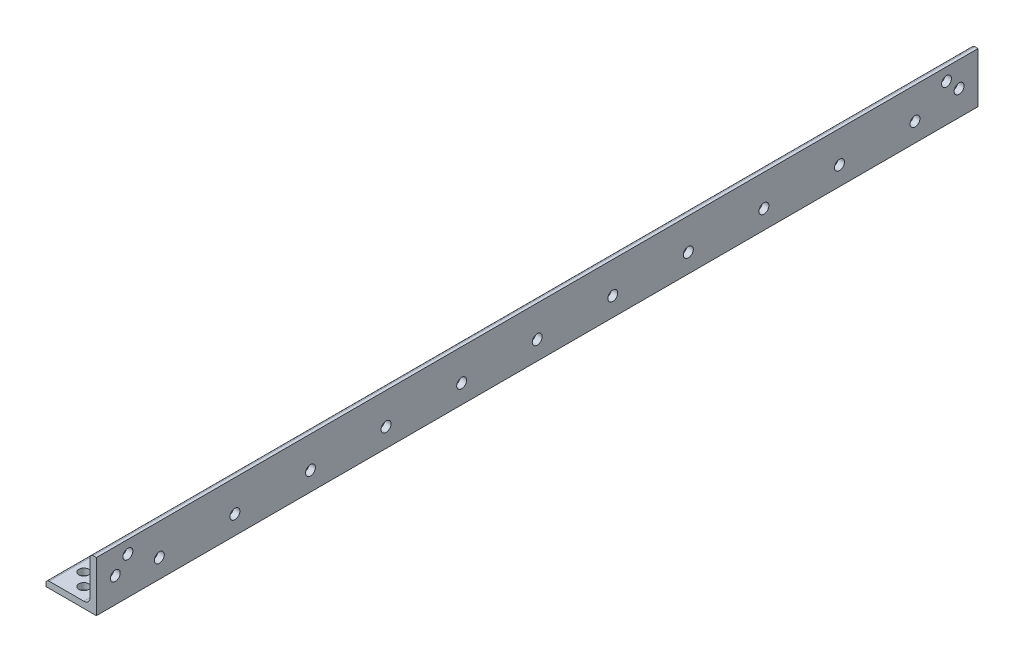
from build123d import *

# Parameters (mm, degrees)
BOSS_EXTRUDE1_DEPTH = 304.8
SKETCH7_W           = 25.4
SKETCH7_H           = 165.1
CUT_EXTRUDE1_DEPTH  = 254
SKETCH3_R           = 2.5
CUT_EXTRUDE2_DEPTH  = 254
SKETCH8_R           = 2.5
CUT_EXTRUDE4_DEPTH  = 254


with BuildPart() as part:
    # Sketch2 → Boss-Extrude1 (new, symmetric)
    with BuildSketch(Plane.XY):
        with BuildLine():
            Line((-12.7, -12.7), (12.7, -12.7))
            Line((12.7, -12.7), (12.7, 12.7))
            Line((12.7, 12.7), (11.1125, 12.7))
            ThreePointArc((11.1125, 12.7), (9.989967985, 12.235032015), (9.525, 11.1125))
            Line((9.525, 11.1125), (9.525, -6.35))
            ThreePointArc((9.525, -6.35), (8.59506403, -8.59506403), (6.35, -9.525))
            Line((6.35, -9.525), (-11.1125, -9.525))
            ThreePointArc((-11.1125, -9.525), (-12.235032015, -9.989967985), (-12.7, -11.1125))
            Line((-12.7, -11.1125), (-12.7, -12.7))
        make_face()
    extrude(amount=BOSS_EXTRUDE1_DEPTH, both=True)

    # Sketch7 → Cut-Extrude1 (cut)
    with BuildSketch(Plane.XZ.offset(12.7)):
        with Locations((0, 222.25)):
            Rectangle(SKETCH7_W, SKETCH7_H)
    extrude(amount=-CUT_EXTRUDE1_DEPTH, mode=Mode.SUBTRACT)

    # Sketch3 → Cut-Extrude2 (cut)
    with BuildSketch(Plane(origin=(0, 0, 0), x_dir=(1, 0, 0), z_dir=(0, 1, 0))):
        with Locations(Location((-6.35, 292.1, 0), (0, 0, 270))):
            Circle(SKETCH3_R)
        with Locations(Location((0, 298.45, 0), (0, 0, 270))):
            Circle(SKETCH3_R)
        with Locations(Location((0, 273.05, 0), (0, 0, 270))):
            Circle(SKETCH3_R)
        with Locations(Location((0, 234.95, 0), (0, 0, 270))):
            Circle(SKETCH3_R)
        with Locations(Location((0, 196.85, 0), (0, 0, 270))):
            Circle(SKETCH3_R)
        with Locations(Location((0, 158.75, 0), (0, 0, 270))):
            Circle(SKETCH3_R)
        with Locations(Location((0, 120.65, 0), (0, 0, 270))):
            Circle(SKETCH3_R)
        with Locations(Location((0, 82.55, 0), (0, 0, 270))):
            Circle(SKETCH3_R)
        with Locations(Location((0, 44.45, 0), (0, 0, 270))):
            Circle(SKETCH3_R)
        with Locations(Location((0, 6.35, 0), (0, 0, 270))):
            Circle(SKETCH3_R)
        with Locations(Location((0, -31.75, 0), (0, 0, 270))):
            Circle(SKETCH3_R)
        with Locations(Location((0, -69.85, 0), (0, 0, 270))):
            Circle(SKETCH3_R)
        with Locations(Location((0, -107.95, 0), (0, 0, 270))):
            Circle(SKETCH3_R)
        with Locations(Location((0, -133.35, 0), (0, 0, 270))):
            Circle(SKETCH3_R)
        with Locations(Location((-6.35, -127, 0), (0, 0, 270))):
            Circle(SKETCH3_R)
    extrude(amount=-CUT_EXTRUDE2_DEPTH, mode=Mode.SUBTRACT)

    # Sketch8 → Cut-Extrude4 (cut)
    with BuildSketch(Plane(origin=(12.7, 0, -12.7), x_dir=(0, 0, 1), z_dir=(-1, 0, 0))):
        with Locations(Location((136.525, 6.35, 0), (0, 0, 90))):
            Circle(SKETCH8_R)
        with Locations(Location((142.875, 0, 0), (0, 0, 90))):
            Circle(SKETCH8_R)
        with Locations(Location((120.65, -3.175, 0), (0, 0, 90))):
            Circle(SKETCH8_R)
        with Locations(Location((82.55, -3.175, 0), (0, 0, 90))):
            Circle(SKETCH8_R)
        with Locations(Location((44.45, -3.175, 0), (0, 0, 90))):
            Circle(SKETCH8_R)
        with Locations(Location((6.35, -3.175, 0), (0, 0, 90))):
            Circle(SKETCH8_R)
        with Locations(Location((-31.75, -3.175, 0), (0, 0, 90))):
            Circle(SKETCH8_R)
        with Locations(Location((-69.85, -3.175, 0), (0, 0, 90))):
            Circle(SKETCH8_R)
        with Locations(Location((-107.95, -3.175, 0), (0, 0, 90))):
            Circle(SKETCH8_R)
        with Locations(Location((-146.05, -3.175, 0), (0, 0, 90))):
            Circle(SKETCH8_R)
        with Locations(Location((-184.15, -3.175, 0), (0, 0, 90))):
            Circle(SKETCH8_R)
        with Locations(Location((-222.25, -3.175, 0), (0, 0, 90))):
            Circle(SKETCH8_R)
        with Locations(Location((-260.35, -3.175, 0), (0, 0, 90))):
            Circle(SKETCH8_R)
        with Locations(Location((-282.575, 0, 0), (0, 0, 90))):
            Circle(SKETCH8_R)
        with Locations(Location((-276.225, 6.35, 0), (0, 0, 90))):
            Circle(SKETCH8_R)
    extrude(amount=CUT_EXTRUDE4_DEPTH, mode=Mode.SUBTRACT)


solid = part.part
